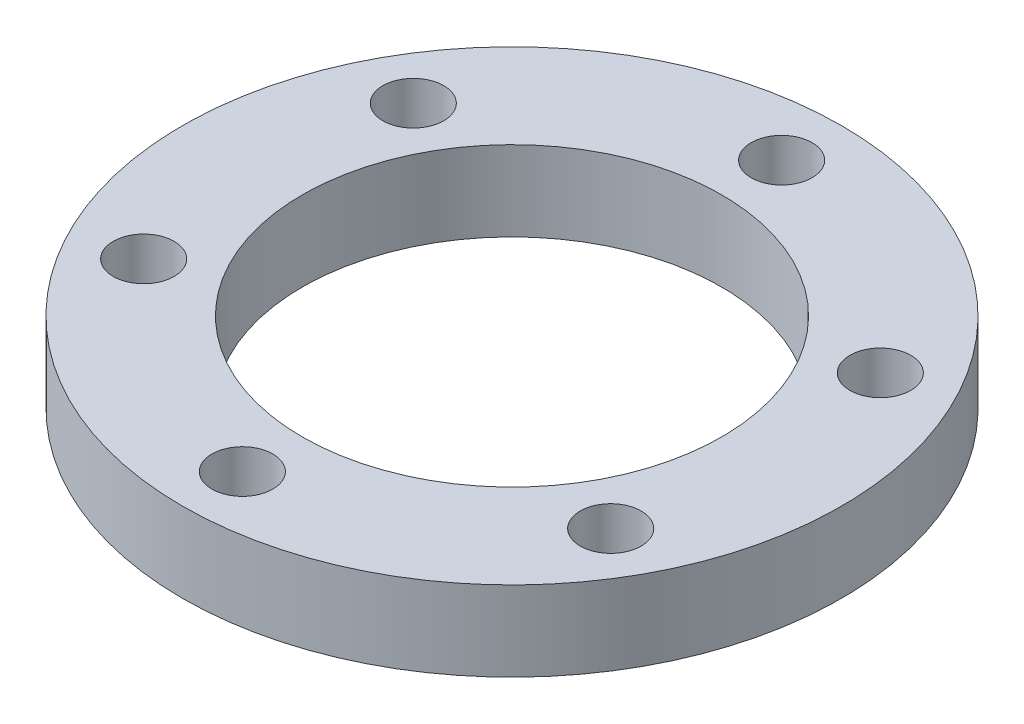
from build123d import *

# Parameters (mm, degrees)
SKETCH_1_R      = 16.5
SKETCH_1_R_2    = 1.525
SKETCH_1_R_3    = 10.5
EXTRUDE_1_DEPTH = 4


with BuildPart() as part:
    # 草图1 → 凸台-拉伸1 (new body)
    with BuildSketch(Plane(origin=(0, 0, 0), x_dir=(1, 0, 0), z_dir=(0, 1, 0))):
        Circle(SKETCH_1_R)
        with Locations((0, 13.5)):
            Circle(SKETCH_1_R_2, mode=Mode.SUBTRACT)
        with Locations((11.691342951, 6.75)):
            Circle(SKETCH_1_R_2, mode=Mode.SUBTRACT)
        with Locations((11.691342951, -6.75)):
            Circle(SKETCH_1_R_2, mode=Mode.SUBTRACT)
        with Locations((0, -13.5)):
            Circle(SKETCH_1_R_2, mode=Mode.SUBTRACT)
        with Locations((-11.691342951, -6.75)):
            Circle(SKETCH_1_R_2, mode=Mode.SUBTRACT)
        with Locations((-11.691342951, 6.75)):
            Circle(SKETCH_1_R_2, mode=Mode.SUBTRACT)
        Circle(SKETCH_1_R_3, mode=Mode.SUBTRACT)
    extrude(amount=EXTRUDE_1_DEPTH)


solid = part.part
